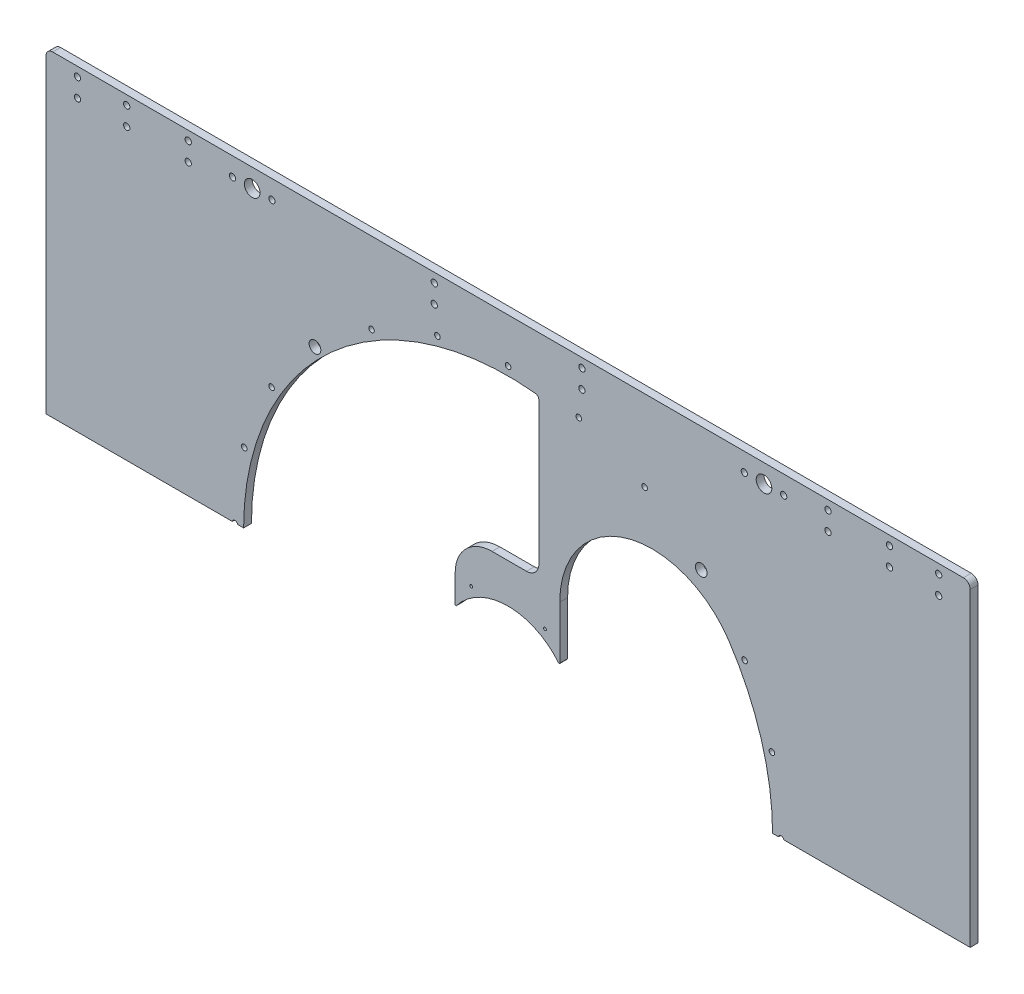
from build123d import *

# Parameters (mm, degrees)
SKETCH1_W                                       = 751.2004
SKETCH1_H                                       = 516
SKETCH1_R                                       = 42.5
BOSS_EXTRUDE2_DEPTH                             = 3.175
FILLET1_R                                       = 25
FILLET4_R                                       = 75
SKETCH2_W                                       = 751.2004
SKETCH2_H                                       = 258
CUT_EXTRUDE1_DEPTH                              = 10
FILLET6_R                                       = 10
FILLET7_R                                       = 30
CSK_FOR_10_FLAT_HEAD_MACHINE_SCREW1_D           = 5.1054
CSK_FOR_10_FLAT_HEAD_MACHINE_SCREW1_CSINK_D     = 9.779
CSK_FOR_10_FLAT_HEAD_MACHINE_SCREW1_CSINK_ANGLE = 82
F_1_2_0_5_DIAMETER_HOLE1_D                      = 12.7
F_1_2_0_5_DIAMETER_HOLE1_DEPTH                  = 129.53
F_1_2_0_5_DIAMETER_HOLE1_TIP                    = 3.815464931
CSK_FOR_M4_FLAT_HEAD_MACHINE_SCREW1_D           = 4.5
CSK_FOR_M4_FLAT_HEAD_MACHINE_SCREW1_CSINK_D     = 9.4
CSK_FOR_M4_FLAT_HEAD_MACHINE_SCREW1_CSINK_ANGLE = 90
CIRPATTERN1_COUNT                               = 24
M4_CLEARANCE_HOLE1_D                            = 4.5
SKETCH12_W                                      = 751.2004
SKETCH12_H                                      = 1
CUT_EXTRUDE2_DEPTH                              = 7.35
FILLET8_R                                       = 3.175
FILLET9_R                                       = 5.5
F_3_8_0_375_DIAMETER_HOLE1_TO_CLEAR_4_MM_D      = 9.525
SKETCH18_R                                      = 53
CUT_EXTRUDE3_DEPTH                              = 7.35
F_4_40_TAPPED_HOLE1_D                           = 2.2606
F_4_40_TAPPED_HOLE1_DEPTH                       = 9.53
F_4_40_TAPPED_HOLE1_TIP                         = 0.679152758
FILLET10_R                                      = 0.5


with BuildPart() as part:
    # Sketch1 → Boss-Extrude2 (new body, symmetric)
    with BuildSketch(Plane.XY):
        Rectangle(SKETCH1_W, SKETCH1_H)
        Circle(SKETCH1_R, mode=Mode.SUBTRACT)
        with BuildLine():
            Line((25, 213.516394277), (25, 85))
            Line((25, 85), (-43, 85))
            Line((-43, 85), (-43, 25.710114741))
            ThreePointArc((-43, 25.710114741), (-50.091092447, -0.94469967), (-42, -27.31318363))
            Line((-42, -27.31318363), (-42, -210.832280794))
            ThreePointArc((-42, -210.832280794), (-212.344530207, 33.526871555), (25, 213.516394277))
        make_face(mode=Mode.SUBTRACT)
        with BuildLine():
            Line((-25, -63), (-25, -213.516394277))
            ThreePointArc((-25, -213.516394277), (212.344530207, -33.526871555), (42, 210.832280794))
            Line((42, 210.832280794), (42, 27.31318363))
            ThreePointArc((42, 27.31318363), (47.61154138, -15.593303928), (17.70508892, -46.867257508))
            Line((17.70508892, -46.867257508), (-25, -63))
        make_face(mode=Mode.SUBTRACT)
    extrude(amount=BOSS_EXTRUDE2_DEPTH, both=True)

    # Fillet1
    fillet1_edges = [part.edges().sort_by_distance(p)[0] for p in [
        (42, 27.31318363, 0),
        (-25, -63, 0),
        (-42, -27.31318363, 0),
    ]]
    fillet(fillet1_edges, radius=FILLET1_R)

    # Fillet4
    fillet4_edges = [part.edges().sort_by_distance(p)[0] for p in [
        (42, 210.832280794, 0),
        (-42, -210.832280794, 0),
    ]]
    fillet(fillet4_edges, radius=FILLET4_R)

    # Sketch2 → Cut-Extrude1 (cut)
    with BuildSketch(Plane(origin=(0, 0, -3.175), x_dir=(-1, 0, 0), z_dir=(0, 0, -1))):
        with Locations((0, -129)):
            Rectangle(SKETCH2_W, SKETCH2_H)
    extrude(amount=-CUT_EXTRUDE1_DEPTH, mode=Mode.SUBTRACT)

    # Fillet6
    fillet6_edges = [part.edges().sort_by_distance(p)[0] for p in [
        (-43, 25.710114741, 0),
        (25, 85, 0),
    ]]
    fillet(fillet6_edges, radius=FILLET6_R)

    # Fillet7
    fillet7_edges = [part.edges().sort_by_distance(p)[0] for p in [
        (-43, 85, 0),
    ]]
    fillet(fillet7_edges, radius=FILLET7_R)

    # CSK for #10 Flat Head Machine Screw1 (through all)
    with Locations(Plane(origin=(0, 0, -3.175), x_dir=(-1, 0, 0), z_dir=(0, 0, -1))):
        with Locations((350, 235.5), (350, 250.5), (60, 235.5), (60, 250.5), (-60, 235.5), (-60, 250.5), (-350, 235.5), (-350, 250.5), (310, 235.5), (310, 250.5), (260, 235.5), (260, 250.5), (-310, 235.5), (-310, 250.5), (-260, 235.5), (-260, 250.5), (224, 243), (192, 243), (-224, 243), (-192, 243)):
            CounterSinkHole(CSK_FOR_10_FLAT_HEAD_MACHINE_SCREW1_D / 2, CSK_FOR_10_FLAT_HEAD_MACHINE_SCREW1_CSINK_D / 2, counter_sink_angle=CSK_FOR_10_FLAT_HEAD_MACHINE_SCREW1_CSINK_ANGLE)

    # 1/2 (0.5) Diameter Hole1
    with Locations(Plane(origin=(0, 0, -3.175), x_dir=(-1, 0, 0), z_dir=(0, 0, -1))):
        with Locations((208, 243), (-208, 243)):
            Hole(F_1_2_0_5_DIAMETER_HOLE1_D / 2, depth=F_1_2_0_5_DIAMETER_HOLE1_DEPTH)
            with Locations((0, 0, -(F_1_2_0_5_DIAMETER_HOLE1_DEPTH + F_1_2_0_5_DIAMETER_HOLE1_TIP / 2))):  # 118° drill point
                Cone(0, F_1_2_0_5_DIAMETER_HOLE1_D / 2, F_1_2_0_5_DIAMETER_HOLE1_TIP, mode=Mode.SUBTRACT)

    # CSK for M4 Flat Head Machine Screw1 (through all)
    with Locations(Plane(origin=(0, 0, -3.175), x_dir=(-1, 0, 0), z_dir=(0, 0, -1))):
        with Locations((0, 222)):
            csk_for_m4_flat_head_machine_screw1 = CounterSinkHole(CSK_FOR_M4_FLAT_HEAD_MACHINE_SCREW1_D / 2, CSK_FOR_M4_FLAT_HEAD_MACHINE_SCREW1_CSINK_D / 2, counter_sink_angle=CSK_FOR_M4_FLAT_HEAD_MACHINE_SCREW1_CSINK_ANGLE)

    # CirPattern1: CSK for M4 Flat Head Machine Screw1 ×24 about axis, 13 skipped
    cirpattern1_axis = Axis((0, 0, 0), (0, 0, 1))
    add([csk_for_m4_flat_head_machine_screw1.rotate(cirpattern1_axis, i * 360 / CIRPATTERN1_COUNT) for i in range(1, CIRPATTERN1_COUNT) if i not in (6, 7, 8, 9, 10, 11, 12, 13, 14, 15, 16, 17, 18)], mode=Mode.SUBTRACT)

    # M4 Clearance Hole1 (through all)
    with Locations(Plane(origin=(0, 0, -3.175), x_dir=(-1, 0, 0), z_dir=(0, 0, -1))):
        with Locations((-222, 0), (222, 0)):
            Hole(M4_CLEARANCE_HOLE1_D / 2)

    # Sketch12 → Cut-Extrude2 (cut, through all)
    with BuildSketch(Plane(origin=(0, 0, -3.175), x_dir=(-1, 0, 0), z_dir=(0, 0, -1))):
        Rectangle(SKETCH12_W, SKETCH12_H)
    extrude(amount=-CUT_EXTRUDE2_DEPTH, mode=Mode.SUBTRACT)

    # Fillet8
    fillet8_edges = [part.edges().sort_by_distance(p)[0] for p in [
        (25, 213.516394277, 0),
    ]]
    fillet(fillet8_edges, radius=FILLET8_R)

    # Fillet9
    fillet9_edges = [part.edges().sort_by_distance(p)[0] for p in [
        (-375.6002, 258, 0),
        (375.6002, 258, 0),
    ]]
    fillet(fillet9_edges, radius=FILLET9_R)

    # 3/8 (0.375) Diameter Hole1 to clear  4 mm cap screw (through all)
    with Locations(Plane(origin=(0, 0, -3.175), x_dir=(-1, 0, 0), z_dir=(0, 0, -1))):
        with Locations((-156.977705423, 156.977705423), (156.977705423, 156.977705423)):
            Hole(F_3_8_0_375_DIAMETER_HOLE1_TO_CLEAR_4_MM_D / 2)

    # Sketch18 → Cut-Extrude3 (cut, through all)
    with BuildSketch(Plane(origin=(0, 0, -3.175), x_dir=(-1, 0, 0), z_dir=(0, 0, -1))):
        Circle(SKETCH18_R)
    extrude(amount=-CUT_EXTRUDE3_DEPTH, mode=Mode.SUBTRACT)

    # #4-40 Tapped Hole1
    with Locations(Plane(origin=(0, 0, -3.175), x_dir=(-1, 0, 0), z_dir=(0, 0, -1))):
        with Locations((-30, 51.961524227), (30, 51.961524227)):
            Hole(F_4_40_TAPPED_HOLE1_D / 2, depth=F_4_40_TAPPED_HOLE1_DEPTH)
            with Locations((0, 0, -(F_4_40_TAPPED_HOLE1_DEPTH + F_4_40_TAPPED_HOLE1_TIP / 2))):  # 118° drill point
                Cone(0, F_4_40_TAPPED_HOLE1_D / 2, F_4_40_TAPPED_HOLE1_TIP, mode=Mode.SUBTRACT)

    # Fillet10
    fillet10_edges = [part.edges().sort_by_distance(p)[0] for p in [
        (42.05604293, 32.253515359, 0),
        (-43, 30.98386677, 0),
    ]]
    fillet(fillet10_edges, radius=FILLET10_R)


solid = part.part
